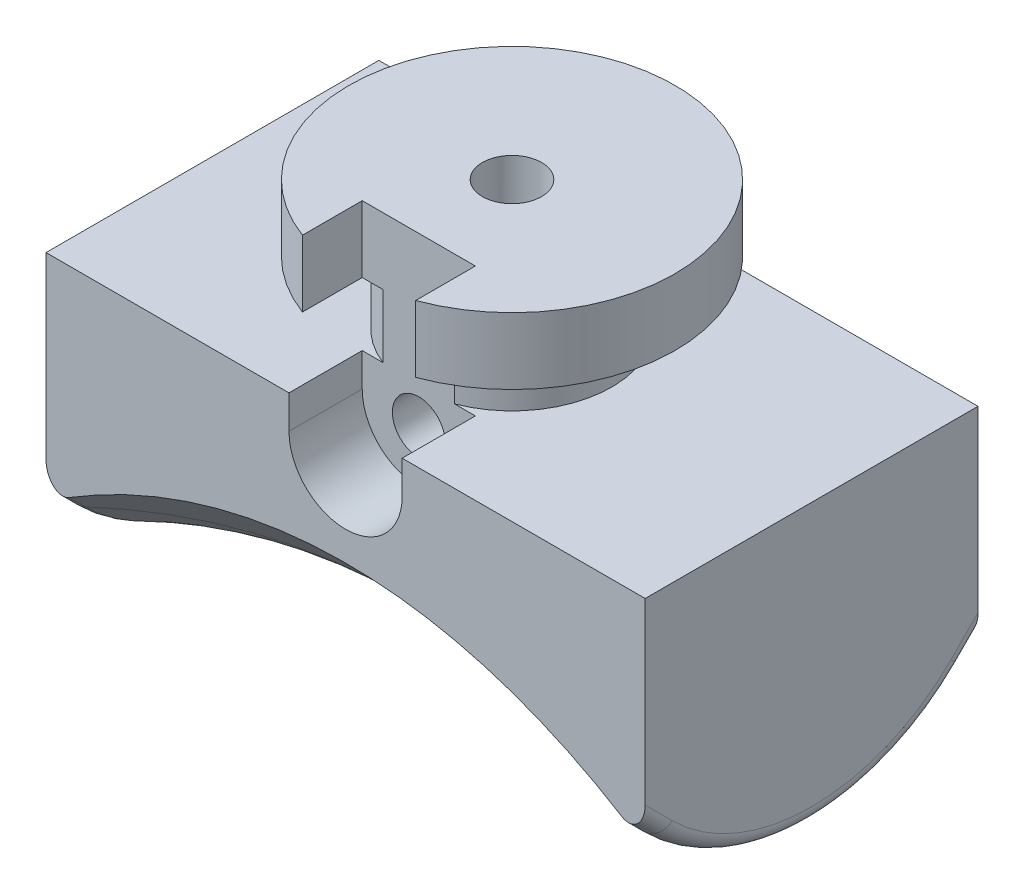
from build123d import *

# Parameters (mm, degrees)
BOSS_EXTRUDE1_DEPTH            = 9
SKETCH4_W                      = 18
SKETCH4_H                      = 44.313566923
CUT_EXTRUDE3_DEPTH             = 6
FILLET1_R                      = 0.5
CUT_EXTRUDE4_DEPTH             = 20
CUT_EXTRUDE5_DEPTH             = 19.0000001
BOSS_EXTRUDE2_DEPTH            = 18
FILLET2_R                      = 3
SKETCH11_OUTSIDE_W             = 65.077
SKETCH11_OUTSIDE_H             = 50.285
SKETCH11_OUTSIDE_W_2           = 10
SKETCH11_OUTSIDE_H_2           = 20
CUT_EXTRUDE6_DEPTH             = 19.0000001
F_2_56_TAPPED_HOLE1_D          = 1.778
F_2_56_TAPPED_HOLE1_DEPTH      = 5.73
F_2_56_TAPPED_HOLE1_TIP        = 0.53416509
CUT_EXTRUDE7_DEPTH             = 2.2
F_1_16_0_0625_DIAMETER_HOLE1_D = 1.5875


with BuildPart() as part:
    # Sketch1 → Boss-Extrude1 (new body, symmetric)
    with BuildSketch(Plane(origin=(0, 0, 0), x_dir=(0, 0, -1), z_dir=(1, 0, 0))):
        with BuildLine():
            Line((3.00520382, -3.00520382), (20, 13.98959236))
            Line((20, 13.98959236), (20, 30))
            Line((20, 30), (0, 30))
            Line((0, 30), (0, -4.25))
            ThreePointArc((0, -4.25), (1.626404588, -3.926488013), (3.00520382, -3.00520382))
        make_face()
    extrude(amount=BOSS_EXTRUDE1_DEPTH, both=True)

    # Sweep1: sweep along a path in Sketch2
    with BuildLine(Plane(origin=(0, 0, 0), x_dir=(0, 0, -1), z_dir=(1, 0, 0))) as sweep1_path:
        Line((20, 13.98959236), (3.00520382, -3.00520382))
        ThreePointArc((3.00520382, -3.00520382), (1.626404588, -3.926488013), (0, -4.25))
    # Sketch3 → Sweep1 (sweep)
    with BuildSketch(Plane.XY):
        with BuildLine():
            Line((9, -4.25), (-9, -4.25))
            Line((-9, -4.25), (-9, -6.701215317))
            ThreePointArc((-9, -6.701215317), (0, -4.65), (9, -6.701215317))
            Line((9, -6.701215317), (9, -4.25))
        make_face()
    sweep(path=sweep1_path.line)

    # Sketch4 → Cut-Extrude3 (cut)
    with BuildSketch(Plane(origin=(0, 0, -20), x_dir=(-1, 0, 0), z_dir=(0, 0, -1))):
        with Locations((0, 7.843216539)):
            Rectangle(SKETCH4_W, SKETCH4_H)
    extrude(amount=CUT_EXTRUDE3_DEPTH, mode=Mode.SUBTRACT)

    # Fillet1
    fillet1_edges = [part.edges().sort_by_distance(p)[0] for p in [
        (9, 2.89228781, -12.369237397),
        (-9, 2.89228781, -12.369237397),
        (9, -6.191115675, -2.564444079),
        (-9, -6.191115675, -2.564444079),
    ]]
    fillet(fillet1_edges, radius=FILLET1_R)

    # Mirror1: part across plane


with BuildPart() as part_1:
    add(part.part)
    add(part.part.mirror(Plane(origin=(9, 30, 0), x_dir=(1, 0, 0), z_dir=(0, 0, -1))))

    # Sketch5 → Cut-Extrude4 (cut, symmetric)
    with BuildSketch(Plane(origin=(0, 0, 0), x_dir=(0, 0, -1), z_dir=(1, 0, 0))):
        Polygon((20, 16), (-7.485561137, 10.657348129), (-11.245391787, 30), (20, 30), align=None)
    extrude(amount=CUT_EXTRUDE4_DEPTH, both=True, mode=Mode.SUBTRACT)

    # Sketch8 → Cut-Extrude5 (cut, through all)
    with BuildSketch(Plane.ZY.offset(9)):
        Polygon((10.6659344, 27.018950173), (20, 28), (20, 30), (11.245391787, 30), align=None)
    extrude(amount=-CUT_EXTRUDE5_DEPTH, mode=Mode.SUBTRACT)

    # Sketch10 → Boss-Extrude2 (add)
    with BuildSketch(Plane.ZY.offset(9)):
        Polygon((20, 28), (29.945218954, 29.045284633), (30.258804343, 26.061718947), (20, 24.983475161), align=None)
    extrude(amount=-BOSS_EXTRUDE2_DEPTH)

    # Fillet2
    fillet2_edges = [part_1.edges().sort_by_distance(p)[0] for p in [
        (0, 24.983475161, 20),
        (0, 10.657348129, 7.485561137),
    ]]
    fillet(fillet2_edges, radius=FILLET2_R)

    # Sketch11 outside → Cut-Extrude6 (cut, through all)
    with BuildSketch(Plane.ZY.offset(9)):
        with Locations((5.1295, 11.3115)):
            Rectangle(SKETCH11_OUTSIDE_W, SKETCH11_OUTSIDE_H)
        with Locations((0, -8)):
            Rectangle(SKETCH11_OUTSIDE_W_2, SKETCH11_OUTSIDE_H_2, mode=Mode.SUBTRACT)
    extrude(amount=-CUT_EXTRUDE6_DEPTH, mode=Mode.SUBTRACT)

    # Sketch13 → Revolve1 (revolve)
    with BuildSketch(Plane(origin=(0, 0, 0), x_dir=(0, 0, -1), z_dir=(1, 0, 0))):
        Polygon((0, 2), (0, 5.9), (-4.9, 5.9), (-4.9, 3.9), (-3, 3.9), (-3, 2), align=None)
    revolve(axis=Axis((0, 0, 0), (0, -1, 0)))

    # #2-56 Tapped Hole1
    with Locations(Plane(origin=(0, 5.9, 0), x_dir=(1, 0, 0), z_dir=(0, 1, 0))):
        with Locations((0, 0)):
            Hole(F_2_56_TAPPED_HOLE1_D / 2, depth=F_2_56_TAPPED_HOLE1_DEPTH)
            with Locations((0, 0, -(F_2_56_TAPPED_HOLE1_DEPTH + F_2_56_TAPPED_HOLE1_TIP / 2))):  # 118° drill point
                Cone(0, F_2_56_TAPPED_HOLE1_D / 2, F_2_56_TAPPED_HOLE1_TIP, mode=Mode.SUBTRACT)

    # Sketch16 → Cut-Extrude7 (cut)
    with BuildSketch(Plane.XY.offset(5)):
        with BuildLine():
            Line((1.7, 7.96125108), (1.7, 1))
            ThreePointArc((1.7, 1), (0, -0.7), (-1.7, 1))
            Line((-1.7, 1), (-1.7, 7.96125108))
            ThreePointArc((-1.7, 7.96125108), (0, 9.66125108), (1.7, 7.96125108))
        make_face()
    extrude(amount=-CUT_EXTRUDE7_DEPTH, mode=Mode.SUBTRACT)

    # 1/16 (0.0625) Diameter Hole1 (through all)
    with Locations(Plane.XY.offset(2.8)):
        with Locations((0, 0.853308914)):
            Hole(F_1_16_0_0625_DIAMETER_HOLE1_D / 2)


solid = part_1.part
